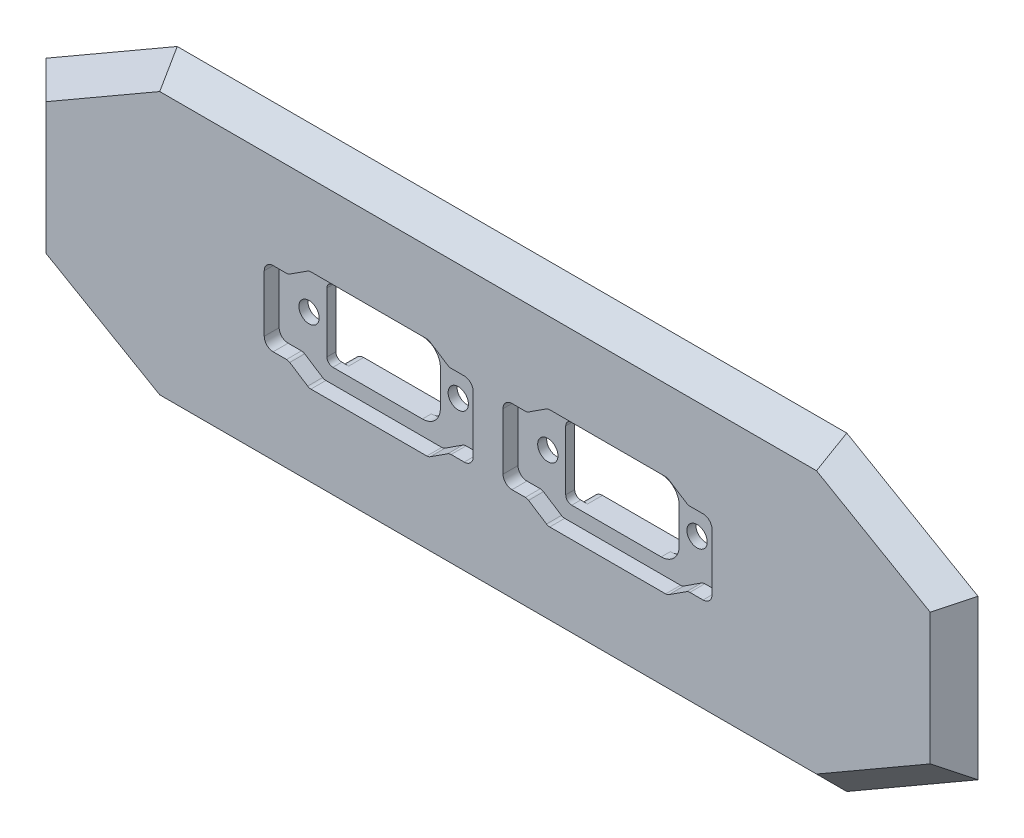
from build123d import *

# Parameters (mm, degrees)
BOSS_EXTRUDE1_DEPTH = 4
BOSS_EXTRUDE2_DEPTH = 2.5
CUT_EXTRUDE1_DEPTH  = 2.5
CUT_EXTRUDE2_DEPTH  = 7.5
SKETCH5_R           = 1.7
CUT_EXTRUDE3_DEPTH  = 5
SKETCH7_OUTSIDE_W   = 218.062
SKETCH7_OUTSIDE_H   = 108.062
CUT_EXTRUDE4_DEPTH  = 7.5
CUT_EXTRUDE4_TAPER  = 45


with BuildPart() as part:
    # Sketch1 → Boss-Extrude1 (new body)
    with BuildSketch(Plane.XY):
        with BuildLine():
            Line((-35, 28), (75, 28))
            ThreePointArc((75, 28), (103, 0), (75, -28))
            Line((75, -28), (-35, -28))
            ThreePointArc((-35, -28), (-63, 0), (-35, 28))
        make_face()
    extrude(amount=BOSS_EXTRUDE1_DEPTH)

    # Sketch2 → Boss-Extrude2 (add)
    with BuildSketch(Plane(origin=(0, 0, 0), x_dir=(-1, 0, 0), z_dir=(0, 0, -1))):
        with BuildLine():
            Line((-7.348469228, -6), (7.348469228, -6))
            ThreePointArc((7.348469228, -6), (8.737199378, -6.93305329), (8.398250547, -8.571428571))
            ThreePointArc((8.398250547, -8.571428571), (0, -12), (-8.398250547, -8.571428571))
            ThreePointArc((-8.398250547, -8.571428571), (-8.737199378, -6.93305329), (-7.348469228, -6))
        make_face()
        with BuildLine():
            Line((7.348469228, 6), (-7.348469228, 6))
            ThreePointArc((-7.348469228, 6), (-8.737199378, 6.93305329), (-8.398250547, 8.571428571))
            ThreePointArc((-8.398250547, 8.571428571), (0, 12), (8.398250547, 8.571428571))
            ThreePointArc((8.398250547, 8.571428571), (8.737199378, 6.93305329), (7.348469228, 6))
        make_face()
        with BuildLine():
            Line((-47.348469228, 6), (-32.651530772, 6))
            ThreePointArc((-32.651530772, 6), (-31.262800622, 6.93305329), (-31.601749453, 8.571428571))
            ThreePointArc((-31.601749453, 8.571428571), (-40, 12), (-48.398250547, 8.571428571))
            ThreePointArc((-48.398250547, 8.571428571), (-48.737199378, 6.93305329), (-47.348469228, 6))
        make_face()
        with BuildLine():
            Line((-32.651530772, -6), (-47.348469228, -6))
            ThreePointArc((-47.348469228, -6), (-48.737199378, -6.93305329), (-48.398250547, -8.571428571))
            ThreePointArc((-48.398250547, -8.571428571), (-40, -12), (-31.601749453, -8.571428571))
            ThreePointArc((-31.601749453, -8.571428571), (-31.262800622, -6.93305329), (-32.651530772, -6))
        make_face()
    extrude(amount=BOSS_EXTRUDE2_DEPTH)

    # Sketch3 → Cut-Extrude1 (cut)
    with BuildSketch(Plane.XY.offset(4)):
        with BuildLine():
            Line((-17.5, 4.75), (-17.5, -4.75))
            ThreePointArc((-17.5, -4.75), (-17.060660172, -5.810660172), (-16, -6.25))
            Line((-16, -6.25), (-13.765564437, -6.25))
            ThreePointArc((-13.765564437, -6.25), (-13.483765285, -6.290526583), (-13.224806846, -6.408821525))
            Line((-13.224806846, -6.408821525), (-10.218918256, -8.341178475))
            ThreePointArc((-10.218918256, -8.341178475), (-9.959959817, -8.459473417), (-9.678160664, -8.5))
            Line((-9.678160664, -8.5), (9.734435563, -8.5))
            ThreePointArc((9.734435563, -8.5), (10.018134319, -8.458913456), (10.278520672, -8.339030031))
            Line((10.278520672, -8.339030031), (13.251769281, -6.410969969))
            ThreePointArc((13.251769281, -6.410969969), (13.512155635, -6.291086544), (13.795854391, -6.25))
            Line((13.795854391, -6.25), (16, -6.25))
            ThreePointArc((16, -6.25), (17.060660172, -5.810660172), (17.5, -4.75))
            Line((17.5, -4.75), (17.5, 4.75))
            ThreePointArc((17.5, 4.75), (17.060660172, 5.810660172), (16, 6.25))
            Line((16, 6.25), (13.793701886, 6.25))
            ThreePointArc((13.793701886, 6.25), (13.511902734, 6.290526583), (13.252944295, 6.408821525))
            Line((13.252944295, 6.408821525), (10.247055705, 8.341178475))
            ThreePointArc((10.247055705, 8.341178475), (9.988097266, 8.459473417), (9.706298114, 8.5))
            Line((9.706298114, 8.5), (-9.704145609, 8.5))
            ThreePointArc((-9.704145609, 8.5), (-9.987844365, 8.458913456), (-10.248230719, 8.339030031))
            Line((-10.248230719, 8.339030031), (-13.221479328, 6.410969969))
            ThreePointArc((-13.221479328, 6.410969969), (-13.481865681, 6.291086544), (-13.765564437, 6.25))
            Line((-13.765564437, 6.25), (-16, 6.25))
            ThreePointArc((-16, 6.25), (-17.060660172, 5.810660172), (-17.5, 4.75))
        make_face()
        with BuildLine():
            Line((22.5, 4.75), (22.5, -4.75))
            ThreePointArc((22.5, -4.75), (22.939339828, -5.810660172), (24, -6.25))
            Line((24, -6.25), (26.234435563, -6.25))
            ThreePointArc((26.234435563, -6.25), (26.516234715, -6.290526583), (26.775193154, -6.408821525))
            Line((26.775193154, -6.408821525), (29.781081744, -8.341178475))
            ThreePointArc((29.781081744, -8.341178475), (30.040040183, -8.459473417), (30.321839336, -8.5))
            Line((30.321839336, -8.5), (49.734435563, -8.5))
            ThreePointArc((49.734435563, -8.5), (50.018134319, -8.458913456), (50.278520672, -8.339030031))
            Line((50.278520672, -8.339030031), (53.251769281, -6.410969969))
            ThreePointArc((53.251769281, -6.410969969), (53.512155635, -6.291086544), (53.795854391, -6.25))
            Line((53.795854391, -6.25), (56, -6.25))
            ThreePointArc((56, -6.25), (57.060660172, -5.810660172), (57.5, -4.75))
            Line((57.5, -4.75), (57.5, 4.75))
            ThreePointArc((57.5, 4.75), (57.060660172, 5.810660172), (56, 6.25))
            Line((56, 6.25), (53.793701886, 6.25))
            ThreePointArc((53.793701886, 6.25), (53.511902734, 6.290526583), (53.252944295, 6.408821525))
            Line((53.252944295, 6.408821525), (50.247055705, 8.341178475))
            ThreePointArc((50.247055705, 8.341178475), (49.988097266, 8.459473417), (49.706298114, 8.5))
            Line((49.706298114, 8.5), (30.295854391, 8.5))
            ThreePointArc((30.295854391, 8.5), (30.012155635, 8.458913456), (29.751769281, 8.339030031))
            Line((29.751769281, 8.339030031), (26.778520672, 6.410969969))
            ThreePointArc((26.778520672, 6.410969969), (26.518134319, 6.291086544), (26.234435563, 6.25))
            Line((26.234435563, 6.25), (24, 6.25))
            ThreePointArc((24, 6.25), (22.939339828, 5.810660172), (22.5, 4.75))
        make_face()
    extrude(amount=-CUT_EXTRUDE1_DEPTH, mode=Mode.SUBTRACT)

    # Sketch4 → Cut-Extrude2 (cut, through all)
    with BuildSketch(Plane(origin=(0, 0, -2.5), x_dir=(-1, 0, 0), z_dir=(0, 0, -1))):
        with BuildLine():
            Line((-6.5, -6), (8.5, -6))
            ThreePointArc((8.5, -6), (9.207106781, -5.707106781), (9.5, -5))
            Line((9.5, -5), (9.5, 5))
            ThreePointArc((9.5, 5), (9.207106781, 5.707106781), (8.5, 6))
            Line((8.5, 6), (-6.5, 6))
            ThreePointArc((-6.5, 6), (-8.621320344, 5.121320344), (-9.5, 3))
            Line((-9.5, 3), (-9.5, -3))
            ThreePointArc((-9.5, -3), (-8.621320344, -5.121320344), (-6.5, -6))
        make_face()
        with BuildLine():
            Line((-46.5, 6), (-31.5, 6))
            ThreePointArc((-31.5, 6), (-30.792893219, 5.707106781), (-30.5, 5))
            Line((-30.5, 5), (-30.5, -5))
            ThreePointArc((-30.5, -5), (-30.792893219, -5.707106781), (-31.5, -6))
            Line((-31.5, -6), (-46.5, -6))
            ThreePointArc((-46.5, -6), (-48.621320344, -5.121320344), (-49.5, -3))
            Line((-49.5, -3), (-49.5, 3))
            ThreePointArc((-49.5, 3), (-48.621320344, 5.121320344), (-46.5, 6))
        make_face()
    extrude(amount=-CUT_EXTRUDE2_DEPTH, mode=Mode.SUBTRACT)

    # Sketch5 → Cut-Extrude3 (cut, through all)
    with BuildSketch(Plane.XY.offset(1.5)):
        with Locations((-12.5, 0)):
            Circle(SKETCH5_R)
        with Locations((12.5, 0)):
            Circle(SKETCH5_R)
        with Locations((27.5, 0)):
            Circle(SKETCH5_R)
        with Locations((52.5, 0)):
            Circle(SKETCH5_R)
    extrude(amount=-CUT_EXTRUDE3_DEPTH, mode=Mode.SUBTRACT)

    # Sketch7 outside → Cut-Extrude4 (cut, through all)
    with BuildSketch(Plane.XY.offset(4)):
        with Locations((20, 0)):
            Rectangle(SKETCH7_OUTSIDE_W, SKETCH7_OUTSIDE_H)
        Polygon((-35, 22), (-54.052558883, 11), (-54.052558883, -11), (-35, -22), (75, -22), (94.052558883, -11), (94.052558883, 11), (75, 22), align=None, mode=Mode.SUBTRACT)
    extrude(amount=-CUT_EXTRUDE4_DEPTH, taper=CUT_EXTRUDE4_TAPER, mode=Mode.SUBTRACT)


solid = part.part
